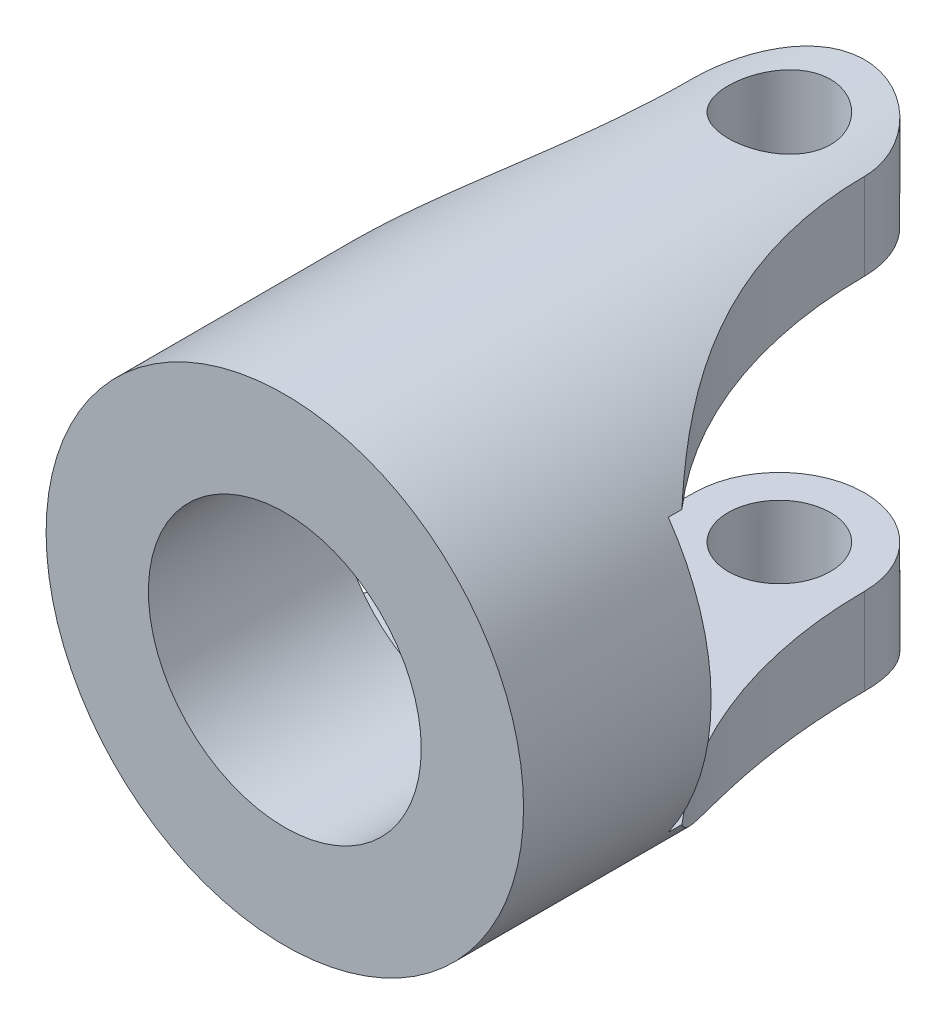
from build123d import *

# Parameters (mm, degrees)
SKETCH1_R               = 7
SKETCH1_R_2             = 4
BOSS_EXTRUDE1_DEPTH     = 17
SKETCH2_R               = 1.5
CUT_EXTRUDE1_DEPTH      = 8
CUT_EXTRUDE1_DEPTH_BACK = 8
SKETCH3_W               = 11.5
SKETCH3_H               = 8
CUT_EXTRUDE2_DEPTH      = 8.0000001
CUT_EXTRUDE2_DEPTH_BACK = 8.0000001


with BuildPart() as part:
    # Sketch1 → Boss-Extrude1 (new body)
    with BuildSketch(Plane.XY):
        Circle(SKETCH1_R)
        Circle(SKETCH1_R_2, mode=Mode.SUBTRACT)
    extrude(amount=BOSS_EXTRUDE1_DEPTH)

    # Sketch2 → Cut-Extrude1 (cut, two sides)
    with BuildSketch(Plane(origin=(0, 0, 0), x_dir=(1, 0, 0), z_dir=(0, 1, 0))) as cut_extrude1_sk:
        with Locations((0, -2.5)):
            Circle(SKETCH2_R)
        with BuildLine():
            Line((-7, -11.5), (-7, 0))
            Line((-7, 0), (0, 1))
            Line((0, 1), (7, 0))
            Line((7, 0), (7, -11.5))
            Line((7, -11.5), (6.109441797, -11.5))
            ThreePointArc((6.109441797, -11.5), (3.435990323, -7.348403606), (2.5, -2.5))
            ThreePointArc((2.5, -2.5), (0, 0), (-2.5, -2.5))
            ThreePointArc((-2.5, -2.5), (-3.435990323, -7.348403606), (-6.109441797, -11.5))
            Line((-6.109441797, -11.5), (-7, -11.5))
        make_face()
    extrude(amount=CUT_EXTRUDE1_DEPTH, mode=Mode.SUBTRACT)
    extrude(cut_extrude1_sk.sketch, amount=-CUT_EXTRUDE1_DEPTH_BACK, mode=Mode.SUBTRACT)

    # Sketch3 → Cut-Extrude2 (cut, two sides)
    with BuildSketch(Plane(origin=(0, 0, 0), x_dir=(0, 0, -1), z_dir=(1, 0, 0))) as cut_extrude2_sk:
        with Locations((-5.75, 0)):
            Rectangle(SKETCH3_W, SKETCH3_H)
    extrude(amount=CUT_EXTRUDE2_DEPTH, mode=Mode.SUBTRACT)
    extrude(cut_extrude2_sk.sketch, amount=-CUT_EXTRUDE2_DEPTH_BACK, mode=Mode.SUBTRACT)


solid = part.part
